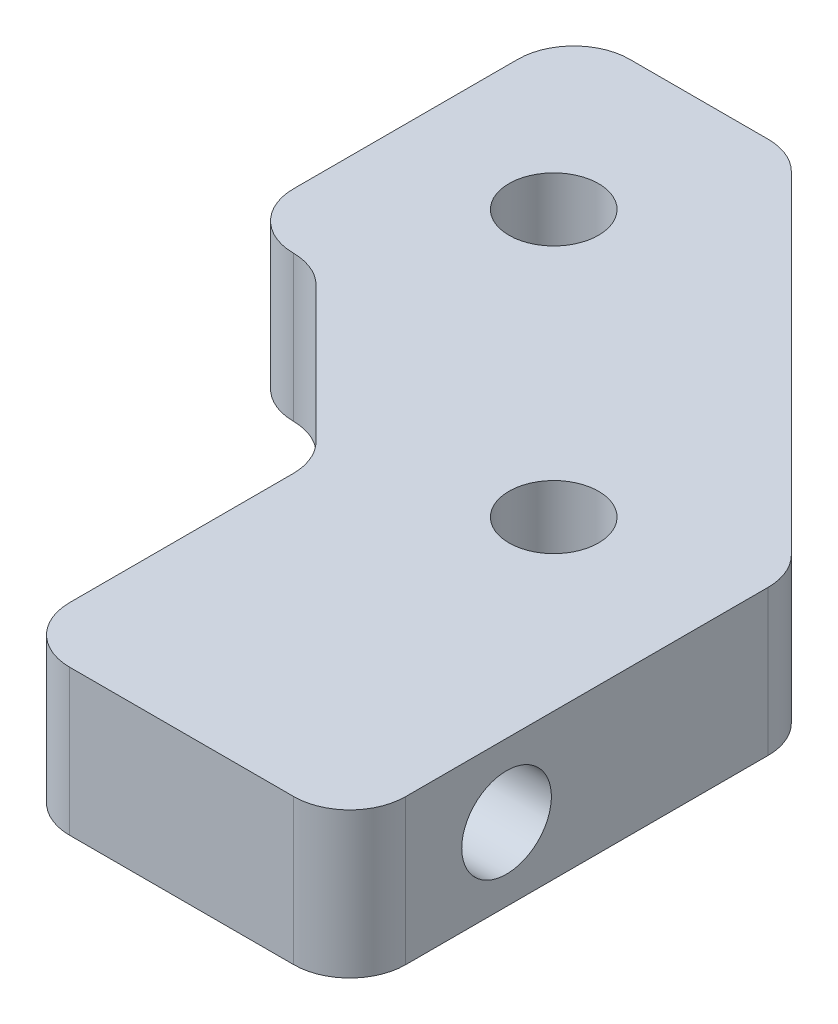
from build123d import *

# Parameters (mm, degrees)
SKETCH1_R      = 4
EXTRUDE1_DEPTH = 13
FILLET5_R      = 5
FILLET6_R      = 5
SKETCH8_R      = 4
EXTRUDE7_DEPTH = 30


with BuildPart() as part:
    # Sketch1 → Extrude1 (new body)
    with BuildSketch(Plane(origin=(0, 0, 0), x_dir=(1, 0, 0), z_dir=(0, 1, 0))):
        Polygon((0, -15), (-15, 0), (-22, 0), (-22, 30), (-2.573593129, 30), (30, -2.573593129), (30, -42), (0, -42), align=None)
        with Locations((-8.786796564, 15)):
            Circle(SKETCH1_R, mode=Mode.SUBTRACT)
        with Locations((15, -8.786796564)):
            Circle(SKETCH1_R, mode=Mode.SUBTRACT)
    extrude(amount=EXTRUDE1_DEPTH)

    # Fillet5
    fillet5_edges = [part.edges().sort_by_distance(p)[0] for p in [
        (-2.573593129, 6.5, -30),
        (30, 6.5, 2.573593129),
        (30, 6.5, 42),
        (0, 6.5, 42),
        (0, 6.5, 15),
        (-15, 6.5, 0),
    ]]
    fillet(fillet5_edges, radius=FILLET5_R)

    # Fillet6
    fillet6_edges = [part.edges().sort_by_distance(p)[0] for p in [
        (-22, 6.5, 0),
        (-22, 6.5, -30),
    ]]
    fillet(fillet6_edges, radius=FILLET6_R)

    # Sketch8 → Extrude7 (cut)
    with BuildSketch(Plane.ZY):
        with Locations((28, 6.5)):
            Circle(SKETCH8_R)
    extrude(amount=-EXTRUDE7_DEPTH, mode=Mode.SUBTRACT)


solid = part.part
